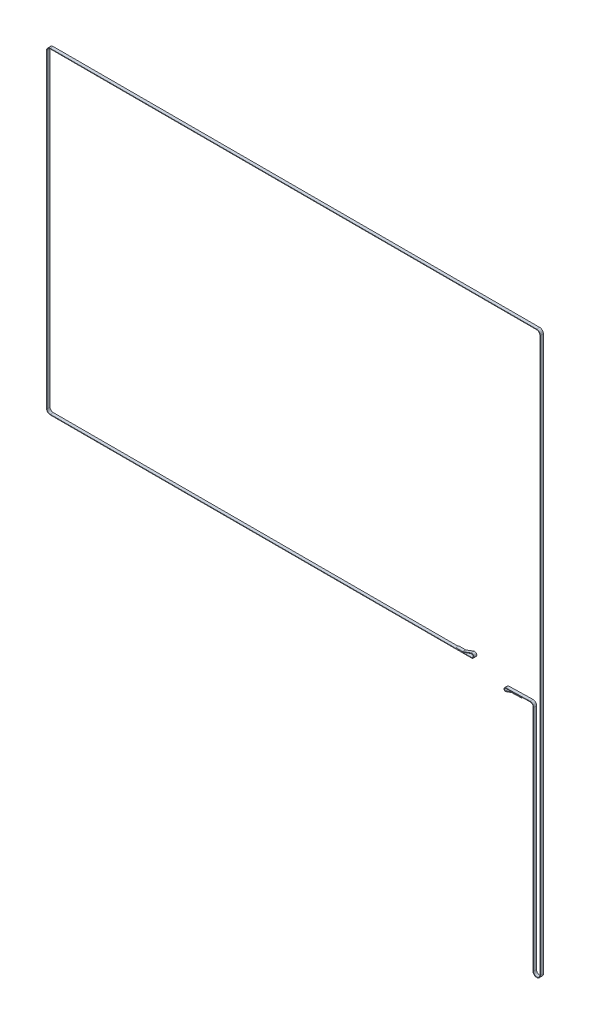
from build123d import *

# Parameters (mm, degrees)
EXTRUDE_THIN4_DEPTH = 6


with BuildPart() as part:
    # Sketch1 → Extrude-Thin4 (new body)
    with BuildSketch(Plane.XY.offset(93.86849497)):
        with BuildLine():
            Line((454.547451712, -84.747722447), (436.143146619, -85.206883154))
            ThreePointArc((436.143146619, -85.206883154), (435.325389653, -85.293870004), (434.532383495, -85.511664405))
            Line((434.532383495, -85.511664405), (424.523003293, -89.154780862))
            ThreePointArc((424.523003293, -89.154780862), (420.309165105, -86.756830797), (423.355608829, -82.985123303))
            Line((423.355608829, -82.985123303), (471.385170996, -81.786855419))
            ThreePointArc((471.385170996, -81.786855419), (476.52965679, -83.807458497), (478.672495941, -88.902241246))
            Line((478.672495941, -88.902241246), (478.192503637, -538.093193208))
            ThreePointArc((478.192503637, -538.093193208), (484.559857096, -544.469999452), (490.932499818, -538.098479016))
            Line((490.932499818, -538.098479016), (490.672499826, 550.801458903))
            ThreePointArc((490.672499826, 550.801458903), (488.882406602, 555.120938203), (484.5625, 556.91))
            Line((484.5625, 556.91), (-471.5625, 556.91))
            ThreePointArc((-471.5625, 556.91), (-475.882922433, 555.120422433), (-477.6725, 550.8))
            Line((-477.6725, 550.8), (-477.6725, -58.894643712))
            ThreePointArc((-477.6725, -58.894643712), (-475.882402145, -63.215586371), (-471.56102849, -65.004643535))
            Line((-471.56102849, -65.004643535), (356.760717872, -64.80515362))
            ThreePointArc((356.760717872, -64.80515362), (359.892804832, -61.071108191), (355.671900131, -58.634506563))
            Line((355.671900131, -58.634506563), (340.245690102, -64.249187841))
            ThreePointArc((340.245690102, -64.249187841), (339.390962941, -64.478266451), (338.509451222, -64.55554918))
            Line((338.509451222, -64.55554918), (325.647451712, -64.558646816))
            Line((325.647451712, -64.558646816), (325.647210875, -63.558646845))
            Line((325.647210875, -63.558646845), (338.509210386, -63.555549209))
            ThreePointArc((338.509210386, -63.555549209), (339.217196175, -63.493479616), (339.903669959, -63.30949522))
            Line((339.903669959, -63.30949522), (355.329879987, -57.694813942))
            ThreePointArc((355.329879987, -57.694813942), (360.877591668, -60.897341426), (356.760958708, -65.805153591))
            Line((356.760958708, -65.805153591), (-471.560787654, -66.004643506))
            ThreePointArc((-471.560787654, -66.004643506), (-476.589423772, -63.922778296), (-478.6725, -58.894643712))
            Line((-478.6725, -58.894643712), (-478.6725, 550.8))
            ThreePointArc((-478.6725, 550.8), (-476.590029214, 555.827529214), (-471.5625, 557.91))
            Line((-471.5625, 557.91), (484.5625, 557.91))
            ThreePointArc((484.5625, 557.91), (489.589428959, 555.828129398), (491.672499797, 550.801697677))
            Line((491.672499797, 550.801697677), (491.93249979, -538.098240242))
            ThreePointArc((491.93249979, -538.098240242), (484.559442197, -545.469999366), (477.192504208, -538.092124638))
            Line((477.192504208, -538.092124638), (477.672496512, -88.901172676))
            ThreePointArc((477.672496512, -88.901172676), (475.831041208, -84.522955714), (471.410111784, -82.786544349))
            Line((471.410111784, -82.786544349), (423.380549617, -83.984812234))
            ThreePointArc((423.380549617, -83.984812234), (421.29173064, -86.570914228), (424.180983149, -88.215088242))
            Line((424.180983149, -88.215088242), (434.190363351, -84.571971785))
            ThreePointArc((434.190363351, -84.571971785), (435.139473084, -84.31130447), (436.11820583, -84.207194224))
            Line((436.11820583, -84.207194224), (454.522510923, -83.748033516))
            Line((454.522510923, -83.748033516), (454.547451712, -84.747722447))
        make_face()
    extrude(amount=EXTRUDE_THIN4_DEPTH)


solid = part.part
